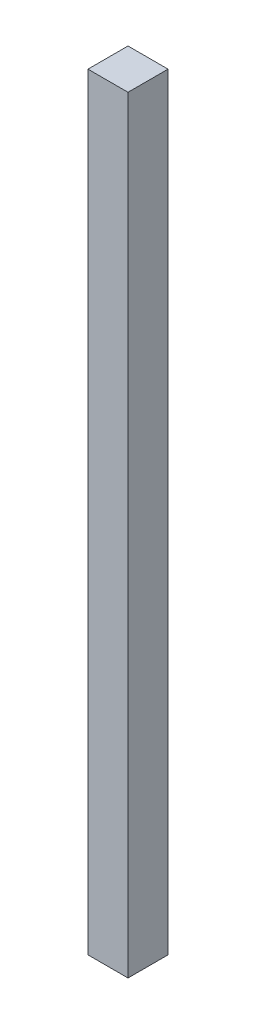
from build123d import *

# Parameters (mm, degrees)
SKETCH1_W           = 25.4
SKETCH1_H           = 25.4
BOSS_EXTRUDE1_DEPTH = 486.41


with BuildPart() as part:
    # Sketch1 → Boss-Extrude1 (new body)
    with BuildSketch(Plane(origin=(0, 0, 0), x_dir=(1, 0, 0), z_dir=(0, 1, 0))):
        with Locations((12.7, 12.7)):
            Rectangle(SKETCH1_W, SKETCH1_H)
    extrude(amount=BOSS_EXTRUDE1_DEPTH)


solid = part.part
